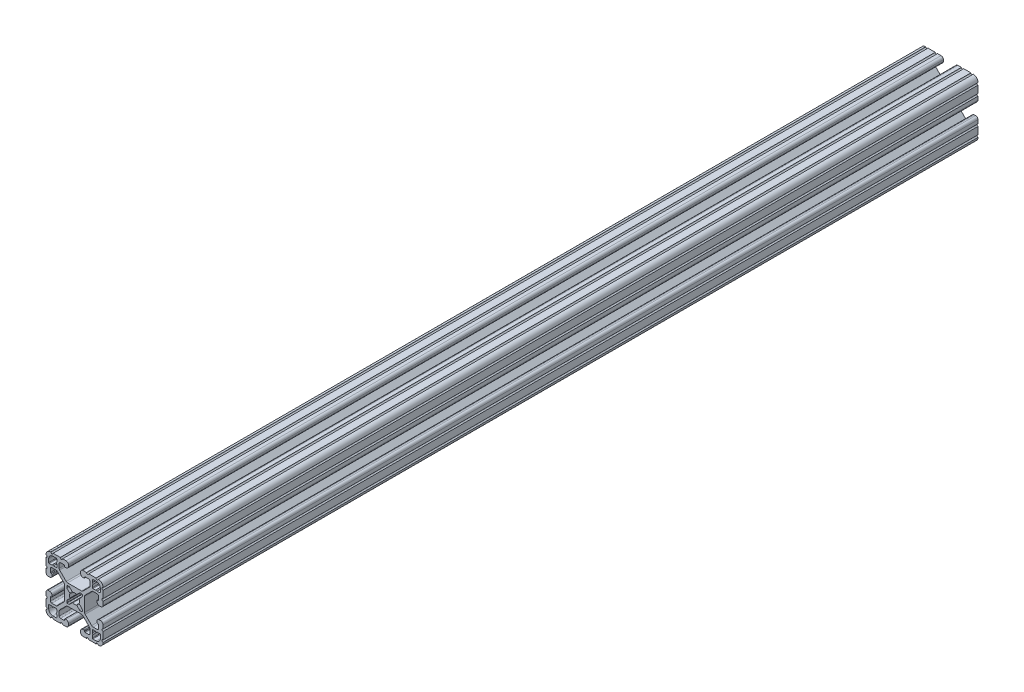
from build123d import *

# Parameters (mm, degrees)
BOSS_EXTRUDE1_DEPTH = 584.2


with BuildPart() as part:
    # Sketch1 → Boss-Extrude1 (new body)
    with BuildSketch(Plane(origin=(0, 0, -2322.576), x_dir=(-1, 0, 0), z_dir=(0, 0, -1))):
        with BuildLine():
            Line((19.05, -14.325600033), (19.05, -9.4996))
            ThreePointArc((19.05, -9.4996), (18.288, -8.7376), (19.05, -7.9756))
            Line((19.05, -7.9756), (19.05, -5.6388))
            ThreePointArc((19.05, -5.6388), (18.588751759, -4.525248241), (17.4752, -4.064))
            Line((17.4752, -4.064), (16.5608, -4.064))
            ThreePointArc((16.5608, -4.064), (15.447248241, -4.525248241), (14.986, -5.6388))
            Line((14.986, -5.6388), (14.986, -6.350014224))
            ThreePointArc((14.986, -6.350014224), (15.097592316, -6.619421908), (15.367, -6.731014224))
            Line((15.367, -6.731014224), (15.6972, -6.731014224))
            ThreePointArc((15.6972, -6.731014224), (15.966607684, -6.84260654), (16.0782, -7.112014224))
            Line((16.0782, -7.112014224), (16.0782, -9.398014224))
            ThreePointArc((16.0782, -9.398014224), (15.817817928, -10.026632152), (15.1892, -10.287014224))
            Line((15.1892, -10.287014224), (12.375630013, -10.287014224))
            ThreePointArc((12.375630013, -10.287014224), (11.889622054, -10.19034123), (11.477604401, -9.915039836))
            Line((11.477604401, -9.915039836), (7.115699788, -5.553135223))
            ThreePointArc((7.115699788, -5.553135223), (6.840398394, -5.14111757), (6.7437254, -4.655109611))
            Line((6.7437254, -4.655109611), (6.7437254, 4.655109611))
            ThreePointArc((6.7437254, 4.655109611), (6.840398394, 5.14111757), (7.115699788, 5.553135223))
            Line((7.115699788, 5.553135223), (11.477604401, 9.915039836))
            ThreePointArc((11.477604401, 9.915039836), (11.889622054, 10.19034123), (12.375630013, 10.287014224))
            Line((12.375630013, 10.287014224), (15.1892, 10.287014224))
            ThreePointArc((15.1892, 10.287014224), (15.817817928, 10.026632152), (16.0782, 9.398014224))
            Line((16.0782, 9.398014224), (16.0782, 7.112014224))
            ThreePointArc((16.0782, 7.112014224), (15.966607684, 6.84260654), (15.6972, 6.731014224))
            Line((15.6972, 6.731014224), (15.367, 6.731014224))
            ThreePointArc((15.367, 6.731014224), (15.097592316, 6.619421908), (14.986, 6.350014224))
            Line((14.986, 6.350014224), (14.986, 5.6388))
            ThreePointArc((14.986, 5.6388), (15.447248241, 4.525248241), (16.5608, 4.064))
            Line((16.5608, 4.064), (17.4752, 4.064))
            ThreePointArc((17.4752, 4.064), (18.588751759, 4.525248241), (19.05, 5.6388))
            Line((19.05, 5.6388), (19.05, 7.9756))
            ThreePointArc((19.05, 7.9756), (18.288, 8.7376), (19.05, 9.4996))
            Line((19.05, 9.4996), (19.05, 14.325599984))
            ThreePointArc((19.05, 14.325599984), (18.287999986, 15.087549208), (19.049898416, 15.849600009))
            ThreePointArc((19.049898416, 15.849600009), (18.120064036, 18.120064058), (15.849599977, 19.049898414))
            ThreePointArc((15.849599977, 19.049898414), (15.0875492, 18.288000035), (14.325600017, 19.050000016))
            Line((14.325600017, 19.050000016), (9.499600001, 19.050000016))
            ThreePointArc((9.499600001, 19.050000016), (8.737600001, 18.288000016), (7.975600001, 19.050000016))
            Line((7.975600001, 19.050000016), (5.638800016, 19.050000016))
            ThreePointArc((5.638800016, 19.050000016), (4.525248257, 18.588751775), (4.064000016, 17.475200016))
            Line((4.064000016, 17.475200016), (4.064000016, 16.5608))
            ThreePointArc((4.064000016, 16.5608), (4.525248257, 15.447248241), (5.638800016, 14.986))
            Line((5.638800016, 14.986), (6.350014224, 14.986))
            ThreePointArc((6.350014224, 14.986), (6.619421908, 15.097592316), (6.731014224, 15.367))
            Line((6.731014224, 15.367), (6.731014224, 15.6972))
            ThreePointArc((6.731014224, 15.6972), (6.84260654, 15.966607684), (7.112014224, 16.0782))
            Line((7.112014224, 16.0782), (9.398014224, 16.0782))
            ThreePointArc((9.398014224, 16.0782), (10.026632152, 15.817817928), (10.287014224, 15.1892))
            Line((10.287014224, 15.1892), (10.287014224, 12.375630013))
            ThreePointArc((10.287014224, 12.375630013), (10.19034123, 11.889622054), (9.915039836, 11.477604401))
            Line((9.915039836, 11.477604401), (5.553135223, 7.115699788))
            ThreePointArc((5.553135223, 7.115699788), (5.14111757, 6.840398394), (4.655109611, 6.7437254))
            Line((4.655109611, 6.7437254), (-4.655109611, 6.7437254))
            ThreePointArc((-4.655109611, 6.7437254), (-5.14111757, 6.840398394), (-5.553135223, 7.115699788))
            Line((-5.553135223, 7.115699788), (-9.915039836, 11.477604401))
            ThreePointArc((-9.915039836, 11.477604401), (-10.19034123, 11.889622054), (-10.287014224, 12.375630013))
            Line((-10.287014224, 12.375630013), (-10.287014224, 15.1892))
            ThreePointArc((-10.287014224, 15.1892), (-10.026632152, 15.817817928), (-9.398014224, 16.0782))
            Line((-9.398014224, 16.0782), (-7.112014224, 16.0782))
            ThreePointArc((-7.112014224, 16.0782), (-6.84260654, 15.966607684), (-6.731014224, 15.6972))
            Line((-6.731014224, 15.6972), (-6.731014224, 15.367))
            ThreePointArc((-6.731014224, 15.367), (-6.619421908, 15.097592316), (-6.350014224, 14.986))
            Line((-6.350014224, 14.986), (-5.638799984, 14.986))
            ThreePointArc((-5.638799984, 14.986), (-4.525248225, 15.447248241), (-4.063999984, 16.5608))
            Line((-4.063999984, 16.5608), (-4.063999984, 17.475200016))
            ThreePointArc((-4.063999984, 17.475200016), (-4.525248225, 18.588751775), (-5.638799984, 19.050000016))
            Line((-5.638799984, 19.050000016), (-7.975599999, 19.050000016))
            ThreePointArc((-7.975599999, 19.050000016), (-8.737599999, 18.288000016), (-9.499599999, 19.050000016))
            Line((-9.499599999, 19.050000016), (-14.325599999, 19.050000016))
            ThreePointArc((-14.325599999, 19.050000016), (-15.087549199, 18.288000018), (-15.849599993, 19.049898416))
            ThreePointArc((-15.849599993, 19.049898416), (-18.120064042, 18.120064036), (-19.049898398, 15.849599976))
            ThreePointArc((-19.049898398, 15.849599976), (-18.288000019, 15.087549199), (-19.05, 14.325600017))
            Line((-19.05, 14.325600017), (-19.05, 9.4996))
            ThreePointArc((-19.05, 9.4996), (-18.288, 8.7376), (-19.05, 7.9756))
            Line((-19.05, 7.9756), (-19.05, 5.6388))
            ThreePointArc((-19.05, 5.6388), (-18.588751759, 4.525248241), (-17.4752, 4.064))
            Line((-17.4752, 4.064), (-16.5608, 4.064))
            ThreePointArc((-16.5608, 4.064), (-15.447248241, 4.525248241), (-14.986, 5.6388))
            Line((-14.986, 5.6388), (-14.986, 6.350014224))
            ThreePointArc((-14.986, 6.350014224), (-15.097592316, 6.619421908), (-15.367, 6.731014224))
            Line((-15.367, 6.731014224), (-15.6972, 6.731014224))
            ThreePointArc((-15.6972, 6.731014224), (-15.966607684, 6.84260654), (-16.0782, 7.112014224))
            Line((-16.0782, 7.112014224), (-16.0782, 9.398014224))
            ThreePointArc((-16.0782, 9.398014224), (-15.817817928, 10.026632152), (-15.1892, 10.287014224))
            Line((-15.1892, 10.287014224), (-12.375630013, 10.287014224))
            ThreePointArc((-12.375630013, 10.287014224), (-11.889622054, 10.19034123), (-11.477604401, 9.915039836))
            Line((-11.477604401, 9.915039836), (-7.115699788, 5.553135223))
            ThreePointArc((-7.115699788, 5.553135223), (-6.840398394, 5.14111757), (-6.7437254, 4.655109611))
            Line((-6.7437254, 4.655109611), (-6.7437254, -4.655109611))
            ThreePointArc((-6.7437254, -4.655109611), (-6.840398394, -5.14111757), (-7.115699788, -5.553135223))
            Line((-7.115699788, -5.553135223), (-11.477604401, -9.915039836))
            ThreePointArc((-11.477604401, -9.915039836), (-11.889622054, -10.19034123), (-12.375630013, -10.287014224))
            Line((-12.375630013, -10.287014224), (-15.1892, -10.287014224))
            ThreePointArc((-15.1892, -10.287014224), (-15.817817928, -10.026632152), (-16.0782, -9.398014224))
            Line((-16.0782, -9.398014224), (-16.0782, -7.112014224))
            ThreePointArc((-16.0782, -7.112014224), (-15.966607684, -6.84260654), (-15.6972, -6.731014224))
            Line((-15.6972, -6.731014224), (-15.367, -6.731014224))
            ThreePointArc((-15.367, -6.731014224), (-15.097592316, -6.619421908), (-14.986, -6.350014224))
            Line((-14.986, -6.350014224), (-14.986, -5.6388))
            ThreePointArc((-14.986, -5.6388), (-15.447248241, -4.525248241), (-16.5608, -4.064))
            Line((-16.5608, -4.064), (-17.4752, -4.064))
            ThreePointArc((-17.4752, -4.064), (-18.588751759, -4.525248241), (-19.05, -5.6388))
            Line((-19.05, -5.6388), (-19.05, -7.9756))
            ThreePointArc((-19.05, -7.9756), (-18.288, -8.7376), (-19.05, -9.4996))
            Line((-19.05, -9.4996), (-19.05, -14.3256))
            ThreePointArc((-19.05, -14.3256), (-18.288000002, -15.0875492), (-19.0498984, -15.849599993))
            ThreePointArc((-19.0498984, -15.849599993), (-18.120064019, -18.120064043), (-15.84959996, -19.049898399))
            ThreePointArc((-15.84959996, -19.049898399), (-15.087549183, -18.288000019), (-14.325600001, -19.050000001))
            Line((-14.325600001, -19.050000001), (-9.499599984, -19.050000001))
            ThreePointArc((-9.499599984, -19.050000001), (-8.737599984, -18.288000001), (-7.975599984, -19.050000001))
            Line((-7.975599984, -19.050000001), (-5.638799984, -19.050000001))
            ThreePointArc((-5.638799984, -19.050000001), (-4.525248225, -18.58875176), (-4.063999984, -17.475200001))
            Line((-4.063999984, -17.475200001), (-4.063999984, -16.5608))
            ThreePointArc((-4.063999984, -16.5608), (-4.525248225, -15.447248241), (-5.638799984, -14.986))
            Line((-5.638799984, -14.986), (-6.350014224, -14.986))
            ThreePointArc((-6.350014224, -14.986), (-6.619421908, -15.097592316), (-6.731014224, -15.367))
            Line((-6.731014224, -15.367), (-6.731014224, -15.6972))
            ThreePointArc((-6.731014224, -15.6972), (-6.84260654, -15.966607684), (-7.112014224, -16.0782))
            Line((-7.112014224, -16.0782), (-9.398014224, -16.0782))
            ThreePointArc((-9.398014224, -16.0782), (-10.026632152, -15.817817928), (-10.287014224, -15.1892))
            Line((-10.287014224, -15.1892), (-10.287014224, -12.375630013))
            ThreePointArc((-10.287014224, -12.375630013), (-10.19034123, -11.889622054), (-9.915039836, -11.477604401))
            Line((-9.915039836, -11.477604401), (-5.553135223, -7.115699788))
            ThreePointArc((-5.553135223, -7.115699788), (-5.14111757, -6.840398394), (-4.655109611, -6.7437254))
            Line((-4.655109611, -6.7437254), (4.655109611, -6.7437254))
            ThreePointArc((4.655109611, -6.7437254), (5.14111757, -6.840398394), (5.553135223, -7.115699788))
            Line((5.553135223, -7.115699788), (9.915039836, -11.477604401))
            ThreePointArc((9.915039836, -11.477604401), (10.19034123, -11.889622054), (10.287014224, -12.375630013))
            Line((10.287014224, -12.375630013), (10.287014224, -15.1892))
            ThreePointArc((10.287014224, -15.1892), (10.026632152, -15.817817928), (9.398014224, -16.0782))
            Line((9.398014224, -16.0782), (7.112014224, -16.0782))
            ThreePointArc((7.112014224, -16.0782), (6.84260654, -15.966607684), (6.731014224, -15.6972))
            Line((6.731014224, -15.6972), (6.731014224, -15.367))
            ThreePointArc((6.731014224, -15.367), (6.619421908, -15.097592316), (6.350014224, -14.986))
            Line((6.350014224, -14.986), (5.638800016, -14.986))
            ThreePointArc((5.638800016, -14.986), (4.525248257, -15.447248241), (4.064000016, -16.5608))
            Line((4.064000016, -16.5608), (4.064000016, -17.475200001))
            ThreePointArc((4.064000016, -17.475200001), (4.525248257, -18.58875176), (5.638800016, -19.050000001))
            Line((5.638800016, -19.050000001), (7.975600016, -19.050000001))
            ThreePointArc((7.975600016, -19.050000001), (8.737600016, -18.288000001), (9.499600016, -19.050000001))
            Line((9.499600016, -19.050000001), (14.325600016, -19.050000001))
            ThreePointArc((14.325600016, -19.050000001), (15.087549216, -18.288000002), (15.849600009, -19.0498984))
            ThreePointArc((15.849600009, -19.0498984), (18.120064059, -18.12006402), (19.049898415, -15.849599961))
            ThreePointArc((19.049898415, -15.849599961), (18.288000034, -15.087549207), (19.05, -14.325600033))
        make_face()
        with BuildLine():
            Line((17.246614224, 14.452614224), (17.246614224, 12.242814224))
            ThreePointArc((17.246614224, 12.242814224), (17.135021908, 11.97340654), (16.865614224, 11.861814224))
            Line((16.865614224, 11.861814224), (15.092694224, 11.861814224))
            Line((15.092694224, 11.861814224), (14.554214224, 12.400294224))
            Line((14.554214224, 12.400294224), (14.015734224, 11.861814224))
            Line((14.015734224, 11.861814224), (12.242814224, 11.861814224))
            ThreePointArc((12.242814224, 11.861814224), (11.97340654, 11.97340654), (11.861814224, 12.242814224))
            Line((11.861814224, 12.242814224), (11.861814224, 14.015734224))
            Line((11.861814224, 14.015734224), (12.400294224, 14.554214224))
            Line((12.400294224, 14.554214224), (11.861814224, 15.092694224))
            Line((11.861814224, 15.092694224), (11.861814224, 16.865614224))
            ThreePointArc((11.861814224, 16.865614224), (11.97340654, 17.135021908), (12.242814224, 17.246614224))
            Line((12.242814224, 17.246614224), (14.452614224, 17.246614224))
            ThreePointArc((14.452614224, 17.246614224), (16.428270571, 16.428270571), (17.246614224, 14.452614224))
        make_face(mode=Mode.SUBTRACT)
        with BuildLine():
            Line((17.246614224, -12.242814224), (17.246614224, -14.452614224))
            ThreePointArc((17.246614224, -14.452614224), (16.428270571, -16.428270571), (14.452614224, -17.246614224))
            Line((14.452614224, -17.246614224), (12.242814224, -17.246614224))
            ThreePointArc((12.242814224, -17.246614224), (11.97340654, -17.135021908), (11.861814224, -16.865614224))
            Line((11.861814224, -16.865614224), (11.861814224, -15.092694224))
            Line((11.861814224, -15.092694224), (12.400294224, -14.554214224))
            Line((12.400294224, -14.554214224), (11.861814224, -14.015734224))
            Line((11.861814224, -14.015734224), (11.861814224, -12.242814224))
            ThreePointArc((11.861814224, -12.242814224), (11.97340654, -11.97340654), (12.242814224, -11.861814224))
            Line((12.242814224, -11.861814224), (14.015734224, -11.861814224))
            Line((14.015734224, -11.861814224), (14.554214224, -12.400294224))
            Line((14.554214224, -12.400294224), (15.092694224, -11.861814224))
            Line((15.092694224, -11.861814224), (16.865614224, -11.861814224))
            ThreePointArc((16.865614224, -11.861814224), (17.135021908, -11.97340654), (17.246614224, -12.242814224))
        make_face(mode=Mode.SUBTRACT)
        with BuildLine():
            Line((5.1689, -3.920689755), (5.1689, -4.9149))
            ThreePointArc((5.1689, -4.9149), (5.094505122, -5.094505122), (4.9149, -5.1689))
            Line((4.9149, -5.1689), (3.920689755, -5.1689))
            ThreePointArc((3.920689755, -5.1689), (3.580484184, -5.101228904), (3.292071827, -4.908517928))
            Line((3.292071827, -4.908517928), (1.582347442, -3.198793543))
            ThreePointArc((1.582347442, -3.198793543), (1.393016011, -3.095711236), (1.178048687, -3.111879183))
            ThreePointArc((1.178048687, -3.111879183), (0, -3.3274), (-1.178048687, -3.111879183))
            ThreePointArc((-1.178048687, -3.111879183), (-1.393016011, -3.095711236), (-1.582347442, -3.198793543))
            Line((-1.582347442, -3.198793543), (-3.292071827, -4.908517928))
            ThreePointArc((-3.292071827, -4.908517928), (-3.580484184, -5.101228904), (-3.920689755, -5.1689))
            Line((-3.920689755, -5.1689), (-4.9149, -5.1689))
            ThreePointArc((-4.9149, -5.1689), (-5.094505122, -5.094505122), (-5.1689, -4.9149))
            Line((-5.1689, -4.9149), (-5.1689, -3.920689755))
            ThreePointArc((-5.1689, -3.920689755), (-5.101228904, -3.580484184), (-4.908517928, -3.292071827))
            Line((-4.908517928, -3.292071827), (-3.198793543, -1.582347442))
            ThreePointArc((-3.198793543, -1.582347442), (-3.095711236, -1.393016011), (-3.111879183, -1.178048687))
            ThreePointArc((-3.111879183, -1.178048687), (-3.3274, 0), (-3.111879183, 1.178048687))
            ThreePointArc((-3.111879183, 1.178048687), (-3.095711236, 1.393016011), (-3.198793543, 1.582347442))
            Line((-3.198793543, 1.582347442), (-4.908517928, 3.292071827))
            ThreePointArc((-4.908517928, 3.292071827), (-5.101228904, 3.580484184), (-5.1689, 3.920689755))
            Line((-5.1689, 3.920689755), (-5.1689, 4.9149))
            ThreePointArc((-5.1689, 4.9149), (-5.094505122, 5.094505122), (-4.9149, 5.1689))
            Line((-4.9149, 5.1689), (-3.920689755, 5.1689))
            ThreePointArc((-3.920689755, 5.1689), (-3.580484184, 5.101228904), (-3.292071827, 4.908517928))
            Line((-3.292071827, 4.908517928), (-1.582347442, 3.198793543))
            ThreePointArc((-1.582347442, 3.198793543), (-1.393016011, 3.095711236), (-1.178048687, 3.111879183))
            ThreePointArc((-1.178048687, 3.111879183), (0, 3.3274), (1.178048687, 3.111879183))
            ThreePointArc((1.178048687, 3.111879183), (1.393016011, 3.095711236), (1.582347442, 3.198793543))
            Line((1.582347442, 3.198793543), (3.292071827, 4.908517928))
            ThreePointArc((3.292071827, 4.908517928), (3.580484184, 5.101228904), (3.920689755, 5.1689))
            Line((3.920689755, 5.1689), (4.9149, 5.1689))
            ThreePointArc((4.9149, 5.1689), (5.094505122, 5.094505122), (5.1689, 4.9149))
            Line((5.1689, 4.9149), (5.1689, 3.920689755))
            ThreePointArc((5.1689, 3.920689755), (5.101228904, 3.580484184), (4.908517928, 3.292071827))
            Line((4.908517928, 3.292071827), (3.198793543, 1.582347442))
            ThreePointArc((3.198793543, 1.582347442), (3.095711236, 1.393016011), (3.111879183, 1.178048687))
            ThreePointArc((3.111879183, 1.178048687), (3.3274, 0), (3.111879183, -1.178048687))
            ThreePointArc((3.111879183, -1.178048687), (3.095711236, -1.393016011), (3.198793543, -1.582347442))
            Line((3.198793543, -1.582347442), (4.908517928, -3.292071827))
            ThreePointArc((4.908517928, -3.292071827), (5.101228904, -3.580484184), (5.1689, -3.920689755))
        make_face(mode=Mode.SUBTRACT)
        with BuildLine():
            Line((-11.861814224, -12.242814224), (-11.861814224, -14.015734224))
            Line((-11.861814224, -14.015734224), (-12.400294224, -14.554214224))
            Line((-12.400294224, -14.554214224), (-11.861814224, -15.092694224))
            Line((-11.861814224, -15.092694224), (-11.861814224, -16.865614224))
            ThreePointArc((-11.861814224, -16.865614224), (-11.97340654, -17.135021908), (-12.242814224, -17.246614224))
            Line((-12.242814224, -17.246614224), (-14.452614224, -17.246614224))
            ThreePointArc((-14.452614224, -17.246614224), (-16.428270571, -16.428270571), (-17.246614224, -14.452614224))
            Line((-17.246614224, -14.452614224), (-17.246614224, -12.242814224))
            ThreePointArc((-17.246614224, -12.242814224), (-17.135021908, -11.97340654), (-16.865614224, -11.861814224))
            Line((-16.865614224, -11.861814224), (-15.092694224, -11.861814224))
            Line((-15.092694224, -11.861814224), (-14.554214224, -12.400294224))
            Line((-14.554214224, -12.400294224), (-14.015734224, -11.861814224))
            Line((-14.015734224, -11.861814224), (-12.242814224, -11.861814224))
            ThreePointArc((-12.242814224, -11.861814224), (-11.97340654, -11.97340654), (-11.861814224, -12.242814224))
        make_face(mode=Mode.SUBTRACT)
        with BuildLine():
            Line((-11.861814224, 16.865614224), (-11.861814224, 15.092694224))
            Line((-11.861814224, 15.092694224), (-12.400294224, 14.554214224))
            Line((-12.400294224, 14.554214224), (-11.861814224, 14.015734224))
            Line((-11.861814224, 14.015734224), (-11.861814224, 12.242814224))
            ThreePointArc((-11.861814224, 12.242814224), (-11.97340654, 11.97340654), (-12.242814224, 11.861814224))
            Line((-12.242814224, 11.861814224), (-14.015734224, 11.861814224))
            Line((-14.015734224, 11.861814224), (-14.554214224, 12.400294224))
            Line((-14.554214224, 12.400294224), (-15.092694224, 11.861814224))
            Line((-15.092694224, 11.861814224), (-16.865614224, 11.861814224))
            ThreePointArc((-16.865614224, 11.861814224), (-17.135021908, 11.97340654), (-17.246614224, 12.242814224))
            Line((-17.246614224, 12.242814224), (-17.246614224, 14.452614224))
            ThreePointArc((-17.246614224, 14.452614224), (-16.428270571, 16.428270571), (-14.452614224, 17.246614224))
            Line((-14.452614224, 17.246614224), (-12.242814224, 17.246614224))
            ThreePointArc((-12.242814224, 17.246614224), (-11.97340654, 17.135021908), (-11.861814224, 16.865614224))
        make_face(mode=Mode.SUBTRACT)
    extrude(amount=-BOSS_EXTRUDE1_DEPTH)


solid = part.part
